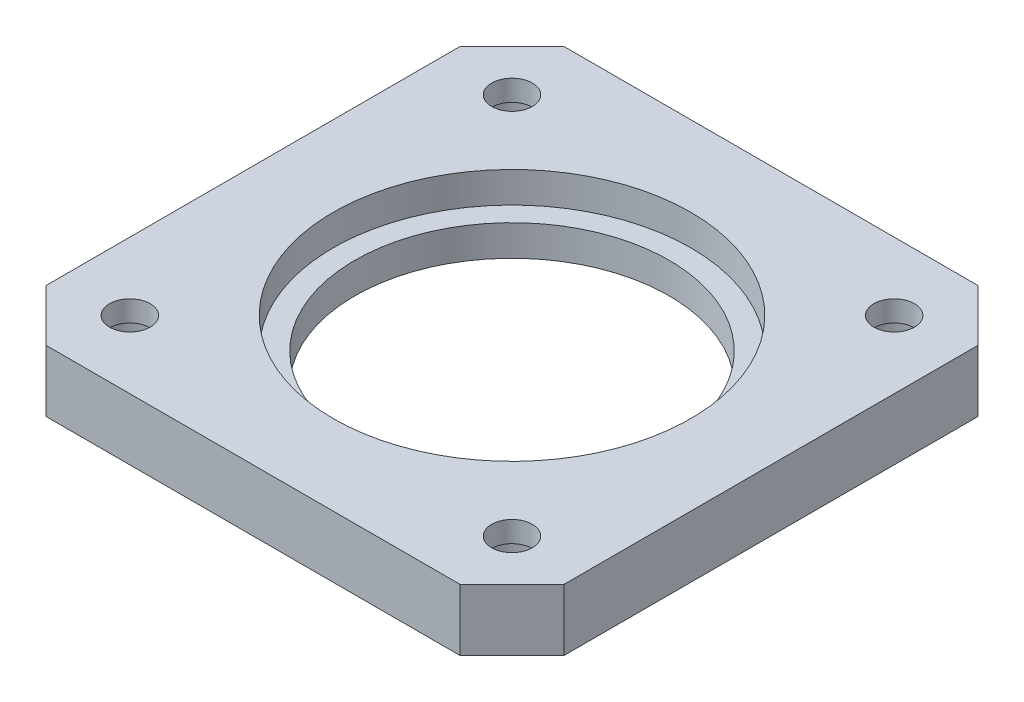
from build123d import *

# Parameters (mm, degrees)
SKETCH_1_W          = 42
SKETCH_1_H          = 42
SKETCH_1_R          = 1.65
SKETCH_1_R_2        = 12.75
EXTRUDE_1_DEPTH     = 5
SKETCH_2_R          = 14.5
CUT_EXTRUDE_1_DEPTH = 2.5
CHAMFER_1_SIZE      = 4.2
SKETCH_3_R          = 1.95
CUT_EXTRUDE_2_DEPTH = 3.2
CHAMFER_2_SIZE      = 0.5
SKETCH_4_R          = 3
CUT_EXTRUDE_3_DEPTH = 3.3


with BuildPart() as part:
    # 草图1 → 凸台-拉伸1 (new body)
    with BuildSketch(Plane(origin=(0, 0, 0), x_dir=(1, 0, 0), z_dir=(0, 1, 0))):
        with Locations((21, 21)):
            Rectangle(SKETCH_1_W, SKETCH_1_H)
        with Locations((5.5, 5.5)):
            Circle(SKETCH_1_R, mode=Mode.SUBTRACT)
        with Locations((36.5, 5.5)):
            Circle(SKETCH_1_R, mode=Mode.SUBTRACT)
        with Locations((36.5, 36.5)):
            Circle(SKETCH_1_R, mode=Mode.SUBTRACT)
        with Locations((5.5, 36.5)):
            Circle(SKETCH_1_R, mode=Mode.SUBTRACT)
        with Locations((21, 21)):
            Circle(SKETCH_1_R_2, mode=Mode.SUBTRACT)
    extrude(amount=EXTRUDE_1_DEPTH)

    # 草图2 → 切除-拉伸1 (cut)
    with BuildSketch(Plane(origin=(0, 5, 0), x_dir=(1, 0, 0), z_dir=(0, 1, 0))):
        with Locations((21, 21)):
            Circle(SKETCH_2_R)
    extrude(amount=-CUT_EXTRUDE_1_DEPTH, mode=Mode.SUBTRACT)

    # 倒角1
    chamfer_1_edges = [part.edges().sort_by_distance(p)[0] for p in [
        (0, 2.5, -42),
        (42, 2.5, -42),
        (42, 2.5, 0),
        (0, 2.5, 0),
    ]]
    chamfer(chamfer_1_edges, length=CHAMFER_1_SIZE)

    # 草图3 → 切除-拉伸2 (cut)
    with BuildSketch(Plane.XZ):
        with Locations((38, -21)):
            Circle(SKETCH_3_R)
        with Locations((21, -38)):
            Circle(SKETCH_3_R)
        with Locations((4, -21)):
            Circle(SKETCH_3_R)
        with Locations((21, -4)):
            Circle(SKETCH_3_R)
    extrude(amount=-CUT_EXTRUDE_2_DEPTH, mode=Mode.SUBTRACT)

    # 倒角2
    chamfer_2_edges = [part.edges().sort_by_distance(p)[0] for p in [
        (36.05, 0, -21),
        (19.05, 0, -38),
        (2.05, 0, -21),
        (19.05, 0, -4),
    ]]
    chamfer(chamfer_2_edges, length=CHAMFER_2_SIZE)

    # 草图4 → 切除-拉伸3 (cut)
    with BuildSketch(Plane.XZ):
        with Locations((5.5, -5.5)):
            Circle(SKETCH_4_R)
        with Locations((36.5, -5.5)):
            Circle(SKETCH_4_R)
        with Locations((36.5, -36.5)):
            Circle(SKETCH_4_R)
        with Locations((5.5, -36.5)):
            Circle(SKETCH_4_R)
    extrude(amount=-CUT_EXTRUDE_3_DEPTH, mode=Mode.SUBTRACT)


solid = part.part
